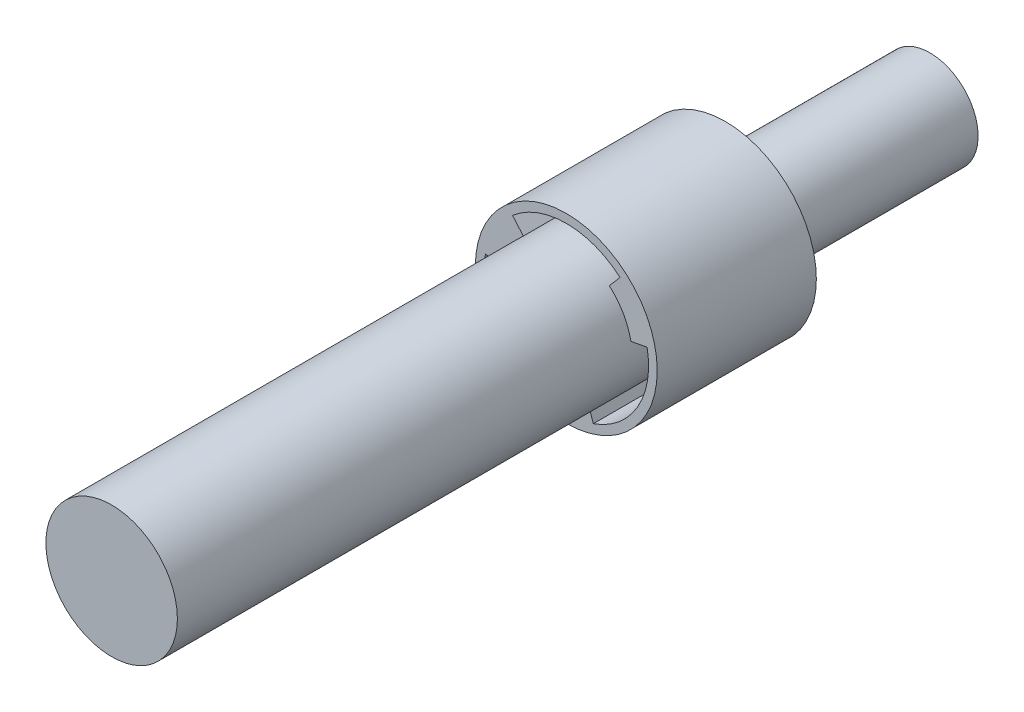
from build123d import *

# Parameters (mm, degrees)
SKETCH1_R           = 14.6939
BOSS_EXTRUDE1_DEPTH = 101.6
SKETCH2_R           = 20.32
BOSS_EXTRUDE2_DEPTH = 35.56
SKETCH3_R           = 10.7442
BOSS_EXTRUDE3_DEPTH = 45.72
CUT_EXTRUDE1_DEPTH  = 14.1986


with BuildPart() as part:
    # Sketch1 → Boss-Extrude1 (new body)
    with BuildSketch(Plane.XY):
        Circle(SKETCH1_R)
    extrude(amount=BOSS_EXTRUDE1_DEPTH)

    # Sketch2 → Boss-Extrude2 (add)
    with BuildSketch(Plane(origin=(0, 0, 0), x_dir=(-1, 0, 0), z_dir=(0, 0, -1))):
        Circle(SKETCH2_R)
    extrude(amount=BOSS_EXTRUDE2_DEPTH)

    # Sketch3 → Boss-Extrude3 (add)
    with BuildSketch(Plane(origin=(0, 0, -35.56), x_dir=(-1, 0, 0), z_dir=(0, 0, -1))):
        Circle(SKETCH3_R)
    extrude(amount=BOSS_EXTRUDE3_DEPTH)

    # Sketch5 → Cut-Extrude1 (cut)
    with BuildSketch(Plane.XY):
        with BuildLine():
            ThreePointArc((-9.602914805, 11.121813002), (0, 14.6939), (9.602914805, 11.121813002))
            Line((9.602914805, 11.121813002), (12.018168226, 13.919088355))
            ThreePointArc((12.018168226, 13.919088355), (0, 18.3896), (-12.018168226, 13.919088355))
            Line((-12.018168226, 13.919088355), (-9.602914805, 11.121813002))
        make_face()
        with BuildLine():
            ThreePointArc((14.433229999, 2.755461671), (12.725290681, -7.34695), (4.830315193, -13.877274673))
            Line((4.830315193, -13.877274673), (6.0452, -17.367583169))
            ThreePointArc((6.0452, -17.367583169), (15.925860765, -9.1948), (18.063368226, 3.448494813))
            Line((18.063368226, 3.448494813), (14.433229999, 2.755461671))
        make_face()
        with BuildLine():
            Line((-6.0452, -17.367583169), (-4.830315193, -13.877274673))
            ThreePointArc((-4.830315193, -13.877274673), (-12.725290681, -7.34695), (-14.433229999, 2.755461671))
            Line((-14.433229999, 2.755461671), (-18.063368226, 3.448494813))
            ThreePointArc((-18.063368226, 3.448494813), (-15.925860765, -9.1948), (-6.0452, -17.367583169))
        make_face()
    extrude(amount=-CUT_EXTRUDE1_DEPTH, mode=Mode.SUBTRACT)


solid = part.part
